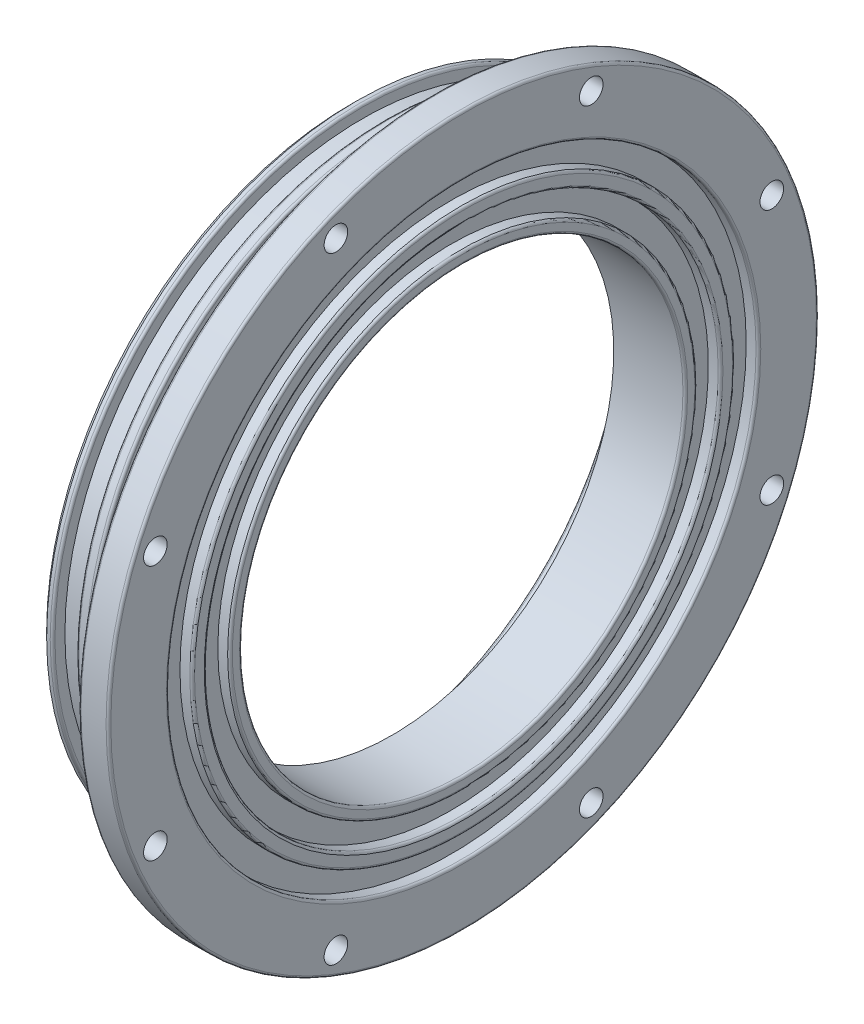
from build123d import *

# Parameters (mm, degrees)
CHAMFER1_SIZE                  = 1.27
FILLET1_R                      = 0.508
F_8_0_199_DIAMETER_HOLE1_D     = 5.0546
F_8_0_199_DIAMETER_HOLE1_DEPTH = 9.149444958
F_8_0_199_DIAMETER_HOLE1_TIP   = 1.518555042
F_4_40_TAPPED_HOLE1_D          = 2.2606
F_4_40_TAPPED_HOLE1_DEPTH      = 6.940847242
F_4_40_TAPPED_HOLE1_TIP        = 0.679152758


with BuildPart() as part:
    # Sketch1 → Revolve1 (revolve)
    with BuildSketch(Plane.XY):
        Polygon((24.19985, -76), (17.829803922, -76), (17.829803922, -66.421), (17.829803922, -66.294), (15.289803922, -66.294), (15.289803922, -63.65748), (10.184901961, -63.65748), (10.184901961, -66.294), (7.644901961, -66.294), (7.644901961, -63.65748), (2.54, -63.65748), (2.54, -66.294), (0, -66.294), (0, -58.42), (8.89, -58.42), (8.89, -47.449486), (24.19985, -47.449486), (24.19985, -49.989486), (21.59, -49.989486), (21.59, -54.989557371), (24.19985, -54.989557371), (24.19985, -58.085736), (21.59, -58.085736), (21.59, -63.085807371), (24.19985, -63.085807371), align=None)
    revolve(axis=Axis((0, 0, 0), (1, 0, 0)))

    # Chamfer1
    chamfer1_edges = [part.edges().sort_by_distance(p)[0] for p in [
        (0, 66.294, 0),
    ]]
    chamfer(chamfer1_edges, length=CHAMFER1_SIZE)

    # Fillet1
    fillet1_edges = [part.edges().sort_by_distance(p)[0] for p in [
        (8.89, 58.42, 0),
        (24.19985, 47.449486, 0),
        (24.19985, 49.989486, 0),
        (24.19985, 54.989557371, 0),
        (24.19985, 58.085736, 0),
        (24.19985, 63.085807371, 0),
        (24.19985, 76, 0),
        (17.829803922, 76, 0),
        (15.289803922, 66.294, 0),
        (10.184901961, 66.294, 0),
        (7.644901961, 66.294, 0),
        (2.54, 66.294, 0),
        (0, 58.42, 0),
    ]]
    fillet(fillet1_edges, radius=FILLET1_R)

    # #8 (0.199) Diameter Hole1
    with Locations(Plane(origin=(24.19985, 0, 0), x_dir=(0, 0, -1), z_dir=(1, 0, 0))):
        with Locations((-65.952711024, 27.318507381), (-27.318507381, 65.952711024), (27.318507381, 65.952711024), (65.952711024, 27.318507381), (65.952711024, -27.318507381), (27.318507381, -65.952711024), (-27.318507381, -65.952711024), (-65.952711024, -27.318507381)):
            Hole(F_8_0_199_DIAMETER_HOLE1_D / 2, depth=F_8_0_199_DIAMETER_HOLE1_DEPTH)
            with Locations((0, 0, -(F_8_0_199_DIAMETER_HOLE1_DEPTH + F_8_0_199_DIAMETER_HOLE1_TIP / 2))):  # 118° drill point
                Cone(0, F_8_0_199_DIAMETER_HOLE1_D / 2, F_8_0_199_DIAMETER_HOLE1_TIP, mode=Mode.SUBTRACT)

    # #4-40 Tapped Hole1
    with Locations(Plane.ZY.offset(-8.89)):
        with Locations((-48.670660215, 20.160047551), (-48.670660215, -20.160047551), (-20.160047551, -48.670660215), (20.160047551, -48.670660215), (48.670660215, -20.160047551), (48.670660215, 20.160047551), (20.160047551, 48.670660215), (-20.160047551, 48.670660215)):
            Hole(F_4_40_TAPPED_HOLE1_D / 2, depth=F_4_40_TAPPED_HOLE1_DEPTH)
            with Locations((0, 0, -(F_4_40_TAPPED_HOLE1_DEPTH + F_4_40_TAPPED_HOLE1_TIP / 2))):  # 118° drill point
                Cone(0, F_4_40_TAPPED_HOLE1_D / 2, F_4_40_TAPPED_HOLE1_TIP, mode=Mode.SUBTRACT)


solid = part.part
